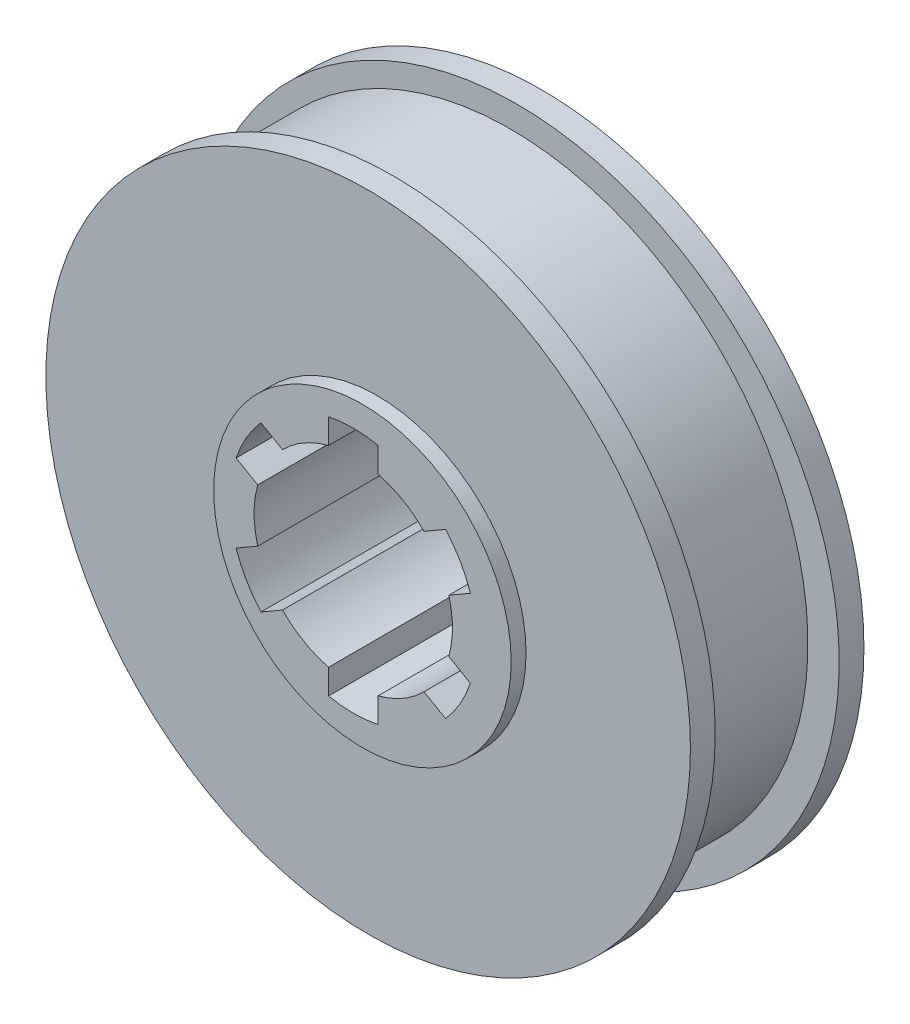
from build123d import *

# Parameters (mm, degrees)
SKETCH1_R           = 6.5
BOSS_EXTRUDE1_DEPTH = 3.5
SKETCH3_R           = 3
BOSS_EXTRUDE2_DEPTH = 0.3
SKETCH4_R           = 6.5
SKETCH4_R_2         = 6
CUT_EXTRUDE1_DEPTH  = 2.5


with BuildPart() as part:
    # Sketch1 → Boss-Extrude1 (new body)
    with BuildSketch(Plane.XY):
        with Locations((0.129947127, 0)):
            Circle(SKETCH1_R)
        with BuildLine():
            Line((-0.370052873, 1.936491673), (-0.370052873, 2.439282681))
            ThreePointArc((-0.370052873, 2.439282681), (0.129947127, 2.49), (0.629947127, 2.439282681))
            Line((0.629947127, 2.439282681), (0.629947127, 1.936491673))
            ThreePointArc((0.629947127, 1.936491673), (1.129947127, 1.732050808), (1.55699811, 1.401258538))
            Line((1.55699811, 1.401258538), (1.992427896, 1.652654043))
            ThreePointArc((1.992427896, 1.652654043), (2.286350382, 1.245), (2.492427896, 0.786628639))
            Line((2.492427896, 0.786628639), (2.05699811, 0.535233135))
            ThreePointArc((2.05699811, 0.535233135), (2.129947127, 0), (2.05699811, -0.535233135))
            Line((2.05699811, -0.535233135), (2.492427896, -0.786628639))
            ThreePointArc((2.492427896, -0.786628639), (2.286350382, -1.245), (1.992427896, -1.652654043))
            Line((1.992427896, -1.652654043), (1.55699811, -1.401258538))
            ThreePointArc((1.55699811, -1.401258538), (1.129947127, -1.732050808), (0.629947127, -1.936491673))
            Line((0.629947127, -1.936491673), (0.629947127, -2.439282681))
            ThreePointArc((0.629947127, -2.439282681), (0.129947127, -2.49), (-0.370052873, -2.439282681))
            Line((-0.370052873, -2.439282681), (-0.370052873, -1.936491673))
            ThreePointArc((-0.370052873, -1.936491673), (-0.870052873, -1.732050808), (-1.297103856, -1.401258538))
            Line((-1.297103856, -1.401258538), (-1.732533642, -1.652654043))
            ThreePointArc((-1.732533642, -1.652654043), (-2.026456129, -1.245), (-2.232533642, -0.786628639))
            Line((-2.232533642, -0.786628639), (-1.797103856, -0.535233135))
            ThreePointArc((-1.797103856, -0.535233135), (-1.870052873, 0), (-1.797103856, 0.535233135))
            Line((-1.797103856, 0.535233135), (-2.232533642, 0.786628639))
            ThreePointArc((-2.232533642, 0.786628639), (-2.026456129, 1.245), (-1.732533642, 1.652654043))
            Line((-1.732533642, 1.652654043), (-1.297103856, 1.401258538))
            ThreePointArc((-1.297103856, 1.401258538), (-0.870052873, 1.732050808), (-0.370052873, 1.936491673))
        make_face(mode=Mode.SUBTRACT)
    extrude(amount=BOSS_EXTRUDE1_DEPTH)

    # Sketch3 → Boss-Extrude2 (add)
    with BuildSketch(Plane.XY.offset(3.5)):
        with Locations((0.314947127, 0)):
            Circle(SKETCH3_R)
        with BuildLine():
            Line((0.629947127, 2.439282681), (0.629947127, 1.936491673))
            ThreePointArc((0.629947127, 1.936491673), (1.129947127, 1.732050808), (1.55699811, 1.401258538))
            Line((1.55699811, 1.401258538), (1.992427896, 1.652654043))
            ThreePointArc((1.992427896, 1.652654043), (2.286350382, 1.245), (2.492427896, 0.786628639))
            Line((2.492427896, 0.786628639), (2.05699811, 0.535233135))
            ThreePointArc((2.05699811, 0.535233135), (2.129947127, 0), (2.05699811, -0.535233135))
            Line((2.05699811, -0.535233135), (2.492427896, -0.786628639))
            ThreePointArc((2.492427896, -0.786628639), (2.286350382, -1.245), (1.992427896, -1.652654043))
            Line((1.992427896, -1.652654043), (1.55699811, -1.401258538))
            ThreePointArc((1.55699811, -1.401258538), (1.129947127, -1.732050808), (0.629947127, -1.936491673))
            Line((0.629947127, -1.936491673), (0.629947127, -2.439282681))
            ThreePointArc((0.629947127, -2.439282681), (0.129947127, -2.49), (-0.370052873, -2.439282681))
            Line((-0.370052873, -2.439282681), (-0.370052873, -1.936491673))
            ThreePointArc((-0.370052873, -1.936491673), (-0.870052873, -1.732050808), (-1.297103856, -1.401258538))
            Line((-1.297103856, -1.401258538), (-1.732533642, -1.652654043))
            ThreePointArc((-1.732533642, -1.652654043), (-2.026456129, -1.245), (-2.232533642, -0.786628639))
            Line((-2.232533642, -0.786628639), (-1.797103856, -0.535233135))
            ThreePointArc((-1.797103856, -0.535233135), (-1.870052873, 0), (-1.797103856, 0.535233135))
            Line((-1.797103856, 0.535233135), (-2.232533642, 0.786628639))
            ThreePointArc((-2.232533642, 0.786628639), (-2.026456129, 1.245), (-1.732533642, 1.652654043))
            Line((-1.732533642, 1.652654043), (-1.297103856, 1.401258538))
            ThreePointArc((-1.297103856, 1.401258538), (-0.870052873, 1.732050808), (-0.370052873, 1.936491673))
            Line((-0.370052873, 1.936491673), (-0.370052873, 2.439282681))
            ThreePointArc((-0.370052873, 2.439282681), (0.129947127, 2.49), (0.629947127, 2.439282681))
        make_face(mode=Mode.SUBTRACT)
    extrude(amount=BOSS_EXTRUDE2_DEPTH)

    # Sketch4 → Cut-Extrude1 (cut)
    with BuildSketch(Plane(origin=(0, 0, 0.5), x_dir=(-1, 0, 0), z_dir=(0, 0, -1))):
        with Locations((-0.129947127, 0)):
            Circle(SKETCH4_R)
        Circle(SKETCH4_R_2, mode=Mode.SUBTRACT)
    extrude(amount=-CUT_EXTRUDE1_DEPTH, mode=Mode.SUBTRACT)


solid = part.part
